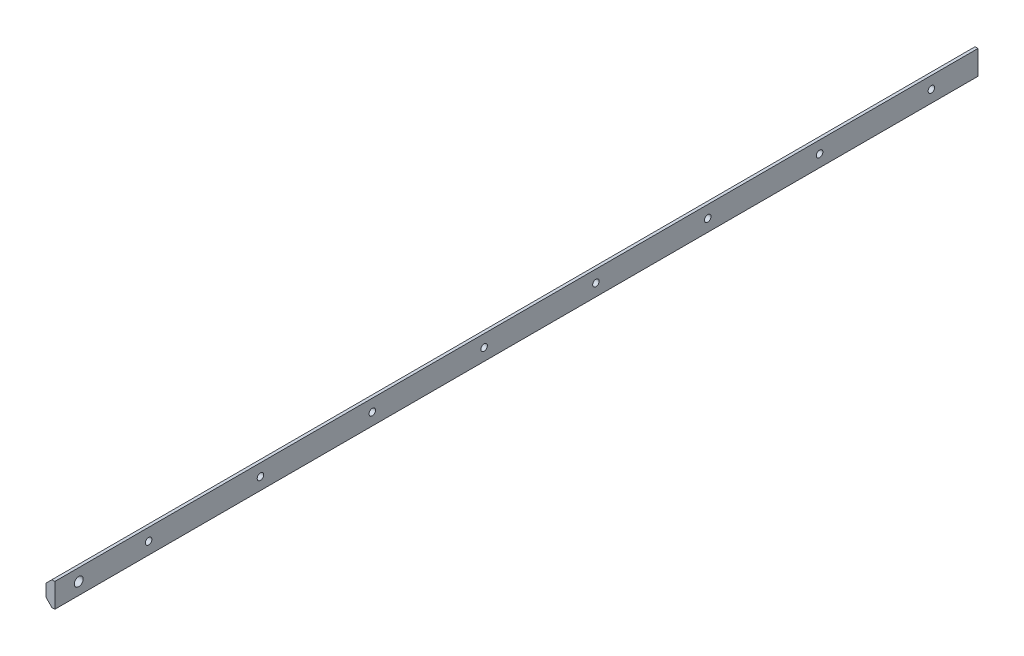
from build123d import *

# Parameters (mm, degrees)
SKETCH1_W                         = 4.7625
SKETCH1_H                         = 12.949588911
BOSS_EXTRUDE1_DEPTH               = 495.29818
F_1_4_0_1875_DIAMETER_HOLE1_D     = 4.7625
F_1_4_0_1875_DIAMETER_HOLE1_DEPTH = 4.7625
CHAMFER1_SIZE                     = 3.175
F_3_0MM_DOWEL_HOLE1_D             = 3.5
F_3_0MM_DOWEL_HOLE1_DEPTH         = 4.7625


with BuildPart() as part:
    # Sketch1 → Boss-Extrude1 (new body)
    with BuildSketch(Plane(origin=(0, 0, 0), x_dir=(-1, 0, 0), z_dir=(0, 0, -1))):
        with Locations((-221.207335178, 186.509282679)):
            Rectangle(SKETCH1_W, SKETCH1_H)
    extrude(amount=BOSS_EXTRUDE1_DEPTH)

    # 1/4 (0.1875) Diameter Hole1
    with Locations(Plane(origin=(223.588585178, 0, 0), x_dir=(0, 0, -1), z_dir=(1, 0, 0))):
        with Locations((12.798180471, 186.509282679)):
            Hole(F_1_4_0_1875_DIAMETER_HOLE1_D / 2, depth=F_1_4_0_1875_DIAMETER_HOLE1_DEPTH)

    # Chamfer1
    chamfer1_edges = [part.edges().sort_by_distance(p)[0] for p in [
        (218.826085178, 180.034488223, -247.64909),
        (218.826085178, 192.984077134, -247.64909),
    ]]
    chamfer(chamfer1_edges, length=CHAMFER1_SIZE)

    # Ø3.0mm Dowel Hole1
    with Locations(Plane(origin=(223.588585178, 0, 0), x_dir=(0, 0, -1), z_dir=(1, 0, 0))):
        with Locations((470.298180445, 186.509282678), (410.298180445, 186.509282678), (350.298180445, 186.509282678), (290.298180445, 186.509282678), (170.298180445, 186.509282678), (110.298180445, 186.509282678), (50.298180445, 186.509282678), (230.298180445, 186.509282678)):
            Hole(F_3_0MM_DOWEL_HOLE1_D / 2, depth=F_3_0MM_DOWEL_HOLE1_DEPTH)


solid = part.part
